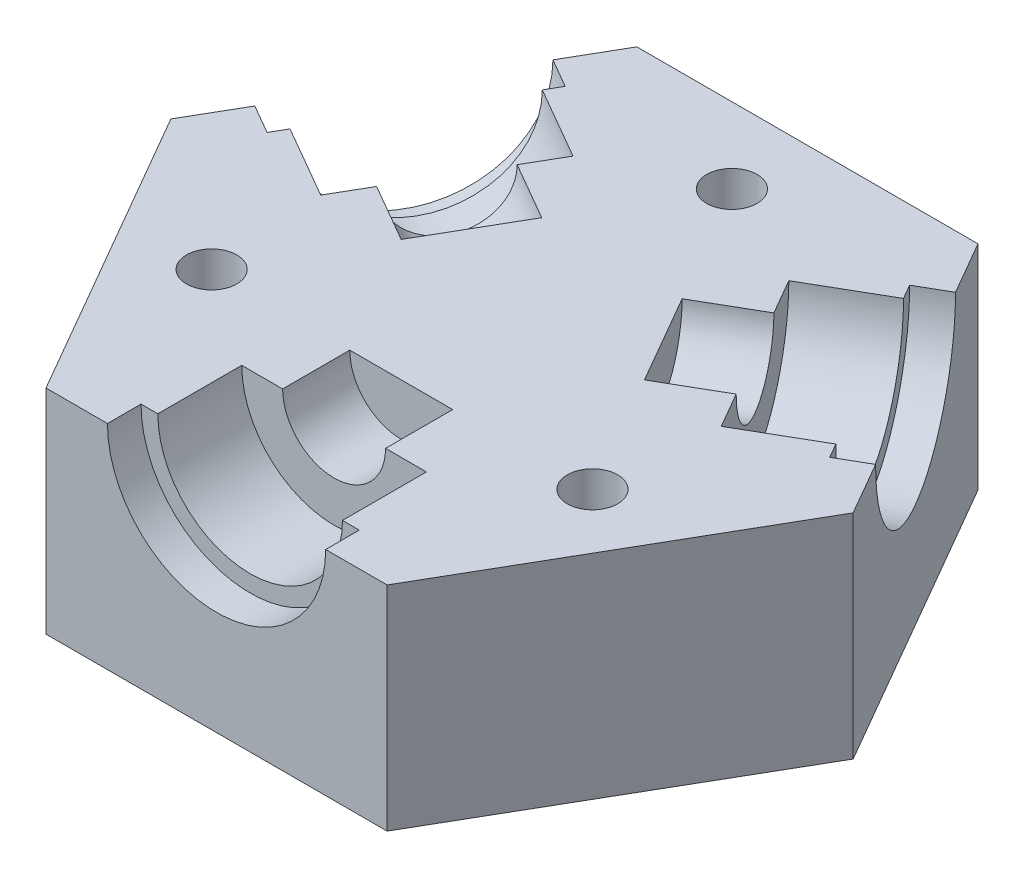
from build123d import *

# Parameters (mm, degrees)
BOSS_EXTRUDE1_DEPTH = 12.7
CIRPATTERN1_COUNT   = 3
SKETCH7_R           = 1.5
CUT_EXTRUDE2_DEPTH  = 6.35


with BuildPart() as part:
    # Sketch1 → Boss-Extrude1 (new body)
    with BuildSketch(Plane(origin=(0, 0, 0), x_dir=(1, 0, 0), z_dir=(0, 1, 0))):
        Polygon((10.16, -17.597636205), (20.32, 0), (10.16, 17.597636205), (-10.16, 17.597636205), (-20.32, 0), (-10.16, -17.597636205), align=None)
    extrude(amount=BOSS_EXTRUDE1_DEPTH)

    # Sketch5 → Cut-Revolve1 (revolve, cut)
    with BuildSketch(Plane(origin=(0, 12.7, 0), x_dir=(1, 0, 0), z_dir=(0, 1, 0))):
        Polygon((0, -17.597636205), (0, -6.597636205), (-3.065310501, -6.597636205), (-3.065310501, -10.597636205), (-5.5, -10.597636205), (-5.5, -15.597636205), (-6.5, -15.597636205), (-6.5, -17.597636205), align=None)
    cut_revolve1 = revolve(axis=Axis((0, 12.7, 17.597636205), (0, 0, -1)), mode=Mode.SUBTRACT)

    # CirPattern1: Cut-Revolve1 ×3 about axis
    cirpattern1_axis = Axis((0, -0.635, 0), (0, 1, 0))
    for i in range(1, CIRPATTERN1_COUNT):
        add(cut_revolve1.rotate(cirpattern1_axis, i * 360 / CIRPATTERN1_COUNT), mode=Mode.SUBTRACT)

    # Sketch7 → Cut-Extrude2 (cut)
    with BuildSketch(Plane(origin=(0, 12.7, 0), x_dir=(1, 0, 0), z_dir=(0, 1, 0))):
        with Locations((0, 13.097636205)):
            Circle(SKETCH7_R)
        with Locations((11.342885683, -6.548818102)):
            Circle(SKETCH7_R)
        with Locations((-11.342885683, -6.548818102)):
            Circle(SKETCH7_R)
    extrude(amount=-CUT_EXTRUDE2_DEPTH, mode=Mode.SUBTRACT)


solid = part.part
